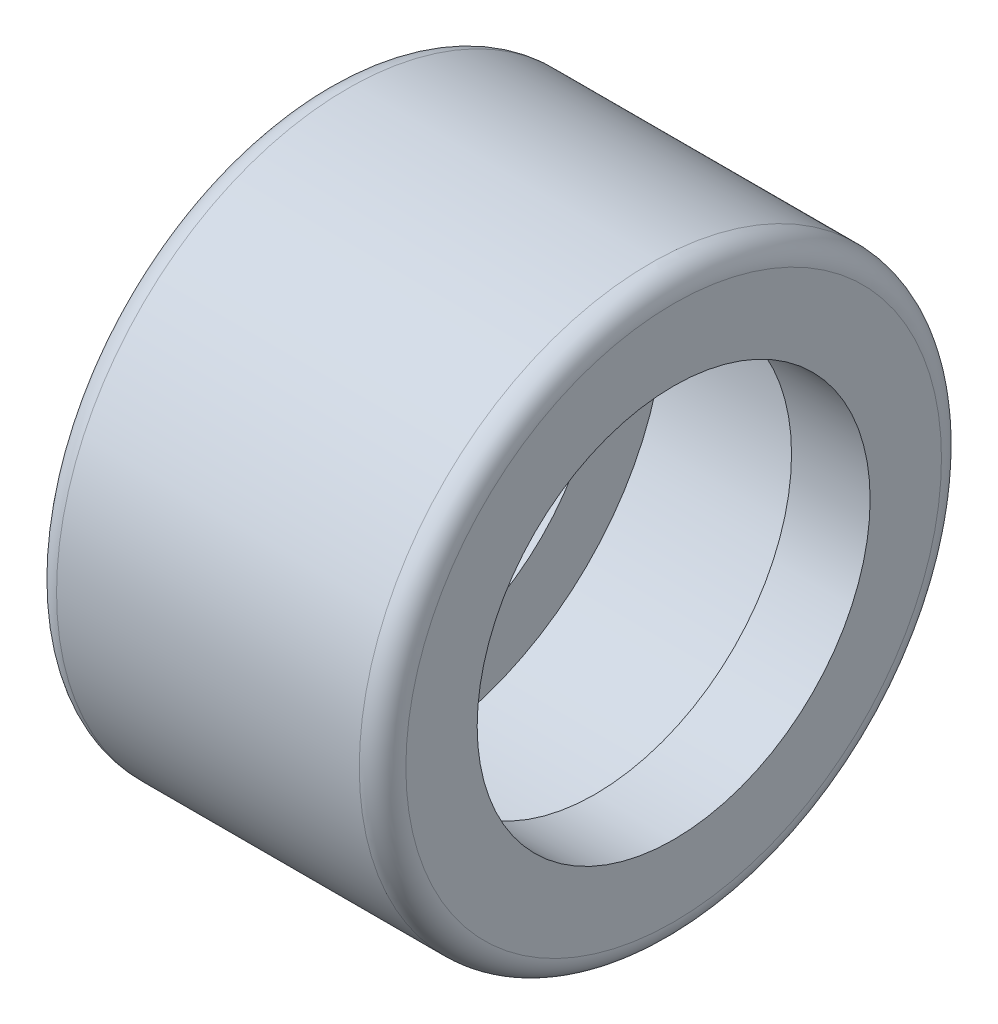
from build123d import *


with BuildPart() as part:
    # Sketch1 → Revolve1 (revolve)
    with BuildSketch(Plane.XY):
        with BuildLine():
            Line((0, 4.6), (0, 3.375))
            Line((0, 3.375), (1.35, 3.375))
            Line((1.35, 3.375), (1.35, 4.5))
            Line((1.35, 4.5), (4.65, 4.5))
            Line((4.65, 4.5), (4.65, 3.375))
            Line((4.65, 3.375), (6, 3.375))
            Line((6, 3.375), (6, 4.6))
            ThreePointArc((6, 4.6), (5.882842712, 4.882842712), (5.6, 5))
            Line((5.6, 5), (0.4, 5))
            ThreePointArc((0.4, 5), (0.117157288, 4.882842712), (0, 4.6))
        make_face()
    revolve(axis=Axis((50, 0, 0), (-1, 0, 0)))


solid = part.part
